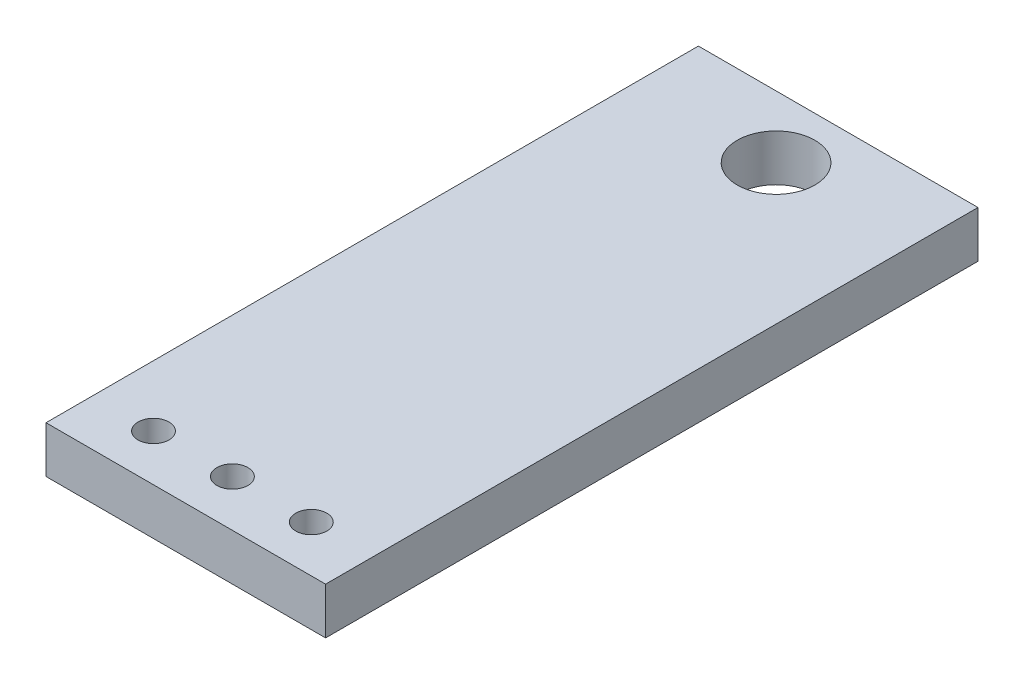
from build123d import *

# Parameters (mm, degrees)
CROQUIS1_W              = 9
CROQUIS1_H              = 21
CROQUIS1_R              = 1.25
CROQUIS1_R_2            = 0.5
SALIENTE_EXTRUIR1_DEPTH = 1.5


with BuildPart() as part:
    # Croquis1 → Saliente-Extruir1 (new body)
    with BuildSketch(Plane(origin=(0, 0, 0), x_dir=(1, 0, 0), z_dir=(0, 1, 0))):
        Rectangle(CROQUIS1_W, CROQUIS1_H)
        with Locations((0, 8.5)):
            Circle(CROQUIS1_R, mode=Mode.SUBTRACT)
        with Locations((-2.54, -9)):
            Circle(CROQUIS1_R_2, mode=Mode.SUBTRACT)
        with Locations((0, -9)):
            Circle(CROQUIS1_R_2, mode=Mode.SUBTRACT)
        with Locations((2.54, -9)):
            Circle(CROQUIS1_R_2, mode=Mode.SUBTRACT)
    extrude(amount=SALIENTE_EXTRUIR1_DEPTH)


solid = part.part
